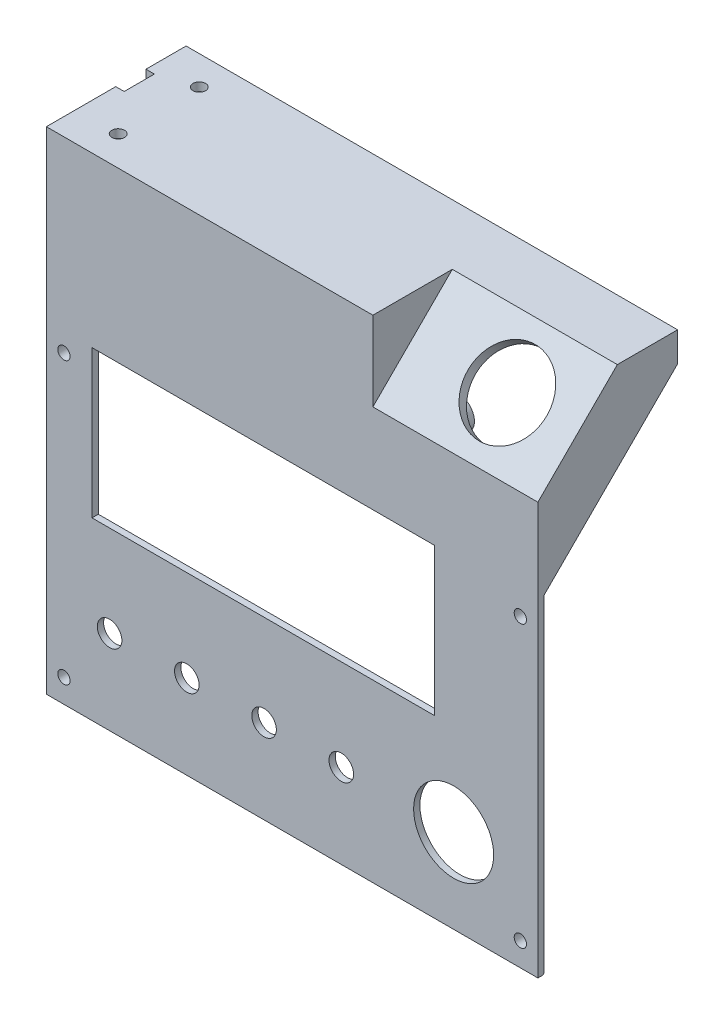
from build123d import *

# Parameters (mm, degrees)
CROQUIS1_W               = 140
CROQUIS1_H               = 140
FRENTE_DEPTH             = 1.8
CROQUIS32_W              = 135.2
CROQUIS32_H              = 135.2
CROQUIS32_W_2            = 132
CROQUIS32_H_2            = 132
SALIENTE_EXTRUIR5_DEPTH  = 2.1
SALIENTE_EXTRUIR6_DEPTH  = 2.1
VISERA_DEPTH             = 38
CORTAR_EXTRUIR1_DEPTH    = 2.4
SALIENTE_EXTRUIR9_DEPTH  = 50
CORTAR_EXTRUIR4_DEPTH    = 47
O_PE_REACH               = 113.138
CROQUIS39_R              = 11.25
CROQUIS15_R              = 1.75
ROSCA_DEPTH              = 3.9
MATRIZL1_COUNT           = 2
MATRIZL1_PITCH           = 80
MATRIZL1_COPY_1_DEPTH    = 2.1
MATRIZL1_COPY_2_SKETCH_R = 1.75
MATRIZL1_COPY_2_DEPTH    = 3.9
VISTA_DISPLAY_REACH      = 3.8
CROQUIS19_W              = 97.6
CROQUIS19_H              = 42
CROQUIS24_R              = 3.5
POTENCIOMETROS_DEPTH     = 1.8
MATRIZL3_COUNT           = 4
MATRIZL3_PITCH           = 22
CORTAR_EXTRUIR2_REACH    = 3.8
CROQUIS36_R              = 11.4
CHAFL_N1_SIZE            = 0.4
MPX_MOUNT_REACH          = 142
CROQUIS40_R              = 1.8
CROQUIS41_R              = 4.3
MPX_TUBBING_DEPTH        = 2.4
CROQUIS210_R             = 5
CROQUIS210_R_2           = 1.2
MEGA_UNO1_DEPTH          = 15
MEGA_UNO1_TAPER          = 1.5


with BuildPart() as part:
    # Croquis1 → FRENTE (new body)
    with BuildSketch(Plane.XY):
        Rectangle(CROQUIS1_W, CROQUIS1_H)
    extrude(amount=FRENTE_DEPTH)

    # Croquis32 → Saliente-Extruir5 (add)
    with BuildSketch(Plane(origin=(0, 0, 0), x_dir=(-1, 0, 0), z_dir=(0, 0, -1))):
        Rectangle(CROQUIS32_W, CROQUIS32_H)
        Rectangle(CROQUIS32_W_2, CROQUIS32_H_2, mode=Mode.SUBTRACT)
    extrude(amount=SALIENTE_EXTRUIR5_DEPTH)

    # Croquis33 → Saliente-Extruir6 (add)
    with BuildSketch(Plane(origin=(0, 0, 0), x_dir=(-1, 0, 0), z_dir=(0, 0, -1))):
        with BuildLine():
            Line((-67.6, -60.260263169), (-67.6, -66.339736831))
            ThreePointArc((-67.6, -66.339736831), (-61, -63.3), (-67.6, -60.260263169))
        make_face()
    saliente_extruir6 = extrude(amount=SALIENTE_EXTRUIR6_DEPTH)

    # Croquis29 → VISERA (add)
    with BuildSketch(Plane(origin=(0, 0, 0), x_dir=(-1, 0, 0), z_dir=(0, 0, -1))):
        Polygon((-70, 23.6), (-70, 70), (0, 70), (0, 67.6), (-67.6, 67.6), (-67.6, 23.6), align=None)
    visera = extrude(amount=VISERA_DEPTH)

    # Croquis30 → Cortar-Extruir1 (cut)
    with BuildSketch(Plane(origin=(70, 0, 0), x_dir=(0, 0, -1), z_dir=(1, 0, 0))):
        Polygon((0, 23.6), (38, 23.6), (38, 61.6), align=None)
    cortar_extruir1 = extrude(amount=-CORTAR_EXTRUIR1_DEPTH, mode=Mode.SUBTRACT)

    # Simetría3: VISERA, Cortar-Extruir1 across plane
    add(visera.mirror(Plane(origin=(0, 0, 0), x_dir=(0, 0, 1), z_dir=(1, 0, 0))))
    add(cortar_extruir1.mirror(Plane(origin=(0, 0, 0), x_dir=(0, 0, 1), z_dir=(1, 0, 0))), mode=Mode.SUBTRACT)

    # Croquis37 → Saliente-Extruir9 (add)
    with BuildSketch(Plane(origin=(70, 0, 0), x_dir=(0, 0, -1), z_dir=(1, 0, 0))):
        Polygon((25.070057685, 70), (-1.8, 43.129942315), (-1.8, 70), align=None)
    extrude(amount=-SALIENTE_EXTRUIR9_DEPTH)

    # Croquis38 → Cortar-Extruir4 (cut)
    with BuildSketch(Plane(origin=(70, 0, 0), x_dir=(0, 0, -1), z_dir=(1, 0, 0))):
        Polygon((20.827416998, 70), (-1.8, 47.372583002), (-1.8, 70), align=None)
    extrude(amount=-CORTAR_EXTRUIR4_DEPTH, mode=Mode.SUBTRACT)

    # Croquis39 → O-PE (cut, up to next)
    with BuildSketch(Plane(origin=(0, 24.586291501, 24.586291501), x_dir=(1, 0, 0), z_dir=(0, 0.707106781, 0.707106781)), mode=Mode.PRIVATE) as o_pe_sk1:
        with Locations((50, 48.224682477)):
            Circle(CROQUIS39_R)
    o_pe_tool1 = extrude(o_pe_sk1.sketch, amount=-O_PE_REACH, mode=Mode.PRIVATE) & part.part
    add(o_pe_tool1.solids().sort_by_distance((50, 58.686292, -9.513708))[0], mode=Mode.SUBTRACT)

    # Croquis15 → ROSCA (cut)
    with BuildSketch(Plane.XY.offset(1.8)):
        with Locations((65, -63.3)):
            Circle(CROQUIS15_R)
    rosca = extrude(amount=-ROSCA_DEPTH, mode=Mode.SUBTRACT)

    # Simetría4: Saliente-Extruir6, ROSCA across plane
    add(saliente_extruir6.mirror(Plane(origin=(0, 0, 0), x_dir=(0, 0, 1), z_dir=(1, 0, 0))))
    add(rosca.mirror(Plane(origin=(0, 0, 0), x_dir=(0, 0, 1), z_dir=(1, 0, 0))), mode=Mode.SUBTRACT)

    # MatrizL1: Saliente-Extruir6, ROSCA ×2
    with Locations(*[(0, i * MATRIZL1_PITCH, 0) for i in range(1, MATRIZL1_COUNT)]):
        add(saliente_extruir6)
        add(rosca, mode=Mode.SUBTRACT)

    # MatrizL1 copy 1 sketch → MatrizL1 copy 1 (add)
    with BuildSketch(Plane(origin=(0, 80, 0), x_dir=(1, 0, 0), z_dir=(0, 0, -1))):
        with BuildLine():
            Line((-67.6, 60.260263169), (-67.6, 66.339736831))
            ThreePointArc((-67.6, 66.339736831), (-61, 63.3), (-67.6, 60.260263169))
        make_face()
    extrude(amount=MATRIZL1_COPY_1_DEPTH)

    # MatrizL1 copy 2 sketch → MatrizL1 copy 2 (cut)
    with BuildSketch(Plane(origin=(0, 80, 1.8), x_dir=(-1, 0, 0), z_dir=(0, 0, 1))):
        with Locations((65, 63.3)):
            Circle(MATRIZL1_COPY_2_SKETCH_R)
    extrude(amount=-MATRIZL1_COPY_2_DEPTH, mode=Mode.SUBTRACT)

    # Croquis19 → VISTA-DISPLAY (cut, up to next)
    with BuildSketch(Plane(origin=(0, 0, 0), x_dir=(-1, 0, 0), z_dir=(0, 0, -1)), mode=Mode.PRIVATE) as vista_display_sk1:
        with Locations((8.2, 1)):
            Rectangle(CROQUIS19_W, CROQUIS19_H)
    vista_display_tool1 = extrude(vista_display_sk1.sketch, amount=-VISTA_DISPLAY_REACH, mode=Mode.PRIVATE) & part.part
    add(vista_display_tool1.solids().sort_by_distance((-8.2, 1, 0))[0], mode=Mode.SUBTRACT)

    # Croquis24 → POTENCIOMETROS (cut)
    with BuildSketch(Plane.XY.offset(1.8)):
        with Locations((-52, -46)):
            Circle(CROQUIS24_R)
    potenciometros = extrude(amount=-POTENCIOMETROS_DEPTH, mode=Mode.SUBTRACT)

    # MatrizL3: POTENCIOMETROS ×4
    with Locations(*[(i * MATRIZL3_PITCH, 0, 0) for i in range(1, MATRIZL3_COUNT)]):
        add(potenciometros, mode=Mode.SUBTRACT)

    # Croquis36 → Cortar-Extruir2 (cut, up to next)
    with BuildSketch(Plane(origin=(0, 0, 0), x_dir=(-1, 0, 0), z_dir=(0, 0, -1)), mode=Mode.PRIVATE) as cortar_extruir2_sk1:
        with Locations((-46, -46)):
            Circle(CROQUIS36_R)
    cortar_extruir2_tool1 = extrude(cortar_extruir2_sk1.sketch, amount=-CORTAR_EXTRUIR2_REACH, mode=Mode.PRIVATE) & part.part
    add(cortar_extruir2_tool1.solids().sort_by_distance((46, -46, 0))[0], mode=Mode.SUBTRACT)

    # Chaflán1
    chafl_n1_edges = [part.edges().sort_by_distance(p)[0] for p in [
        (0, -70, 0),
    ]]
    chamfer(chafl_n1_edges, length=CHAFL_N1_SIZE)

    # Croquis40 → MPX-MOUNT (cut, up to next)
    with BuildSketch(Plane(origin=(0, 70, 0), x_dir=(1, 0, 0), z_dir=(0, 1, 0)), mode=Mode.PRIVATE) as mpx_mount_sk1:
        with Locations((-58, 29.75)):
            Circle(CROQUIS40_R)
    mpx_mount_tool1 = extrude(mpx_mount_sk1.sketch, amount=-MPX_MOUNT_REACH, mode=Mode.PRIVATE) & part.part
    add(mpx_mount_tool1.solids().sort_by_distance((-58, 70, -29.75))[0], mode=Mode.SUBTRACT)
    # Croquis40 → MPX-MOUNT (cut, up to next)
    with BuildSketch(Plane(origin=(0, 70, 0), x_dir=(1, 0, 0), z_dir=(0, 1, 0)), mode=Mode.PRIVATE) as mpx_mount_sk2:
        with Locations((-58, 6.65)):
            Circle(CROQUIS40_R)
    mpx_mount_tool2 = extrude(mpx_mount_sk2.sketch, amount=-MPX_MOUNT_REACH, mode=Mode.PRIVATE) & part.part
    add(mpx_mount_tool2.solids().sort_by_distance((-58, 70, -6.65))[0], mode=Mode.SUBTRACT)

    # Croquis41 → MPX-TUBBING (cut)
    with BuildSketch(Plane.ZY.offset(70)):
        with Locations((-14.13, 58.78)):
            Circle(CROQUIS41_R)
        with BuildLine():
            Line((-26.56, 70), (-26.56, 65.74))
            ThreePointArc((-26.56, 65.74), (-22.26, 61.44), (-17.96, 65.74))
            Line((-17.96, 65.74), (-17.96, 70))
            Line((-17.96, 70), (-26.56, 70))
        make_face()
    extrude(amount=-MPX_TUBBING_DEPTH, mode=Mode.SUBTRACT)

    # Croquis210 → Mega-UNO1 (add)
    with BuildSketch(Plane(origin=(-7.163025125, 18.178552878, 0), x_dir=(-1, 0, 0), z_dir=(0, 0, -1))):
        with Locations((44.866974875, 23.281447122)):
            Circle(CROQUIS210_R)
        with Locations((44.866974875, 23.281447122)):
            Circle(CROQUIS210_R_2, mode=Mode.SUBTRACT)
        with Locations((-7.203025125, 18.201447122)):
            Circle(CROQUIS210_R)
        with Locations((-7.203025125, 18.201447122)):
            Circle(CROQUIS210_R_2, mode=Mode.SUBTRACT)
        with Locations((-37.683025125, 23.281447122)):
            Circle(CROQUIS210_R)
        with Locations((-37.683025125, 23.281447122)):
            Circle(CROQUIS210_R_2, mode=Mode.SUBTRACT)
    extrude(amount=MEGA_UNO1_DEPTH, taper=MEGA_UNO1_TAPER)


solid = part.part
